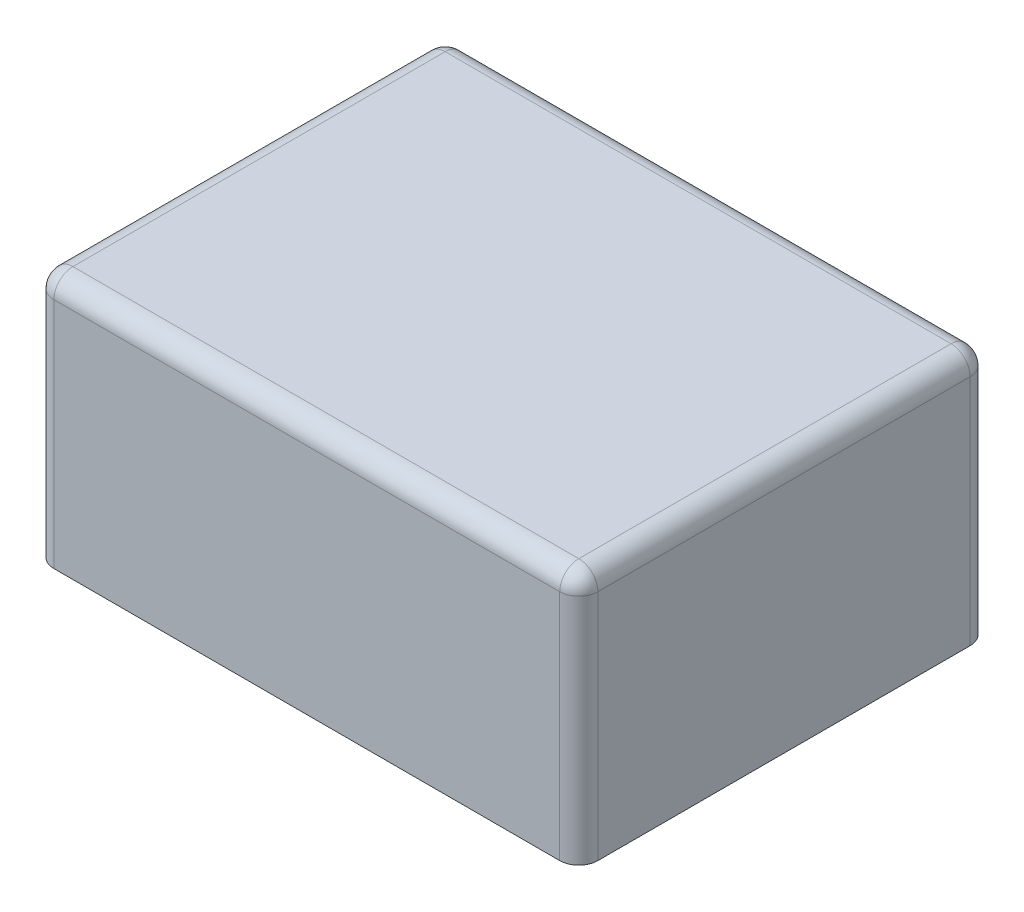
from build123d import *

# Parameters (mm, degrees)
EXTRUDE_1_DEPTH = 13.2
FILLET_1_R      = 1


with BuildPart() as part:
    # 草图1 → 凸台-拉伸1 (new body)
    with BuildSketch(Plane(origin=(0, 0, 0), x_dir=(1, 0, 0), z_dir=(0, 1, 0))):
        with BuildLine():
            Line((1, 0), (27.5, 0))
            ThreePointArc((27.5, 0), (28.207106781, 0.292893219), (28.5, 1))
            Line((28.5, 1), (28.5, 20.5))
            ThreePointArc((28.5, 20.5), (28.207106781, 21.207106781), (27.5, 21.5))
            Line((27.5, 21.5), (1, 21.5))
            ThreePointArc((1, 21.5), (0.292893219, 21.207106781), (0, 20.5))
            Line((0, 20.5), (0, 1))
            ThreePointArc((0, 1), (0.292893219, 0.292893219), (1, 0))
        make_face()
    extrude(amount=EXTRUDE_1_DEPTH)

    # 圆角1
    fillet_1_edges = [part.edges().sort_by_distance(p)[0] for p in [
        (28.207106781, 13.2, -0.292893219),
        (28.5, 13.2, -10.75),
        (28.207106781, 13.2, -21.207106781),
        (14.25, 13.2, -21.5),
        (0.292893219, 13.2, -21.207106781),
        (0, 13.2, -10.75),
        (0.292893219, 13.2, -0.292893219),
        (14.25, 13.2, 0),
    ]]
    fillet(fillet_1_edges, radius=FILLET_1_R)


solid = part.part
